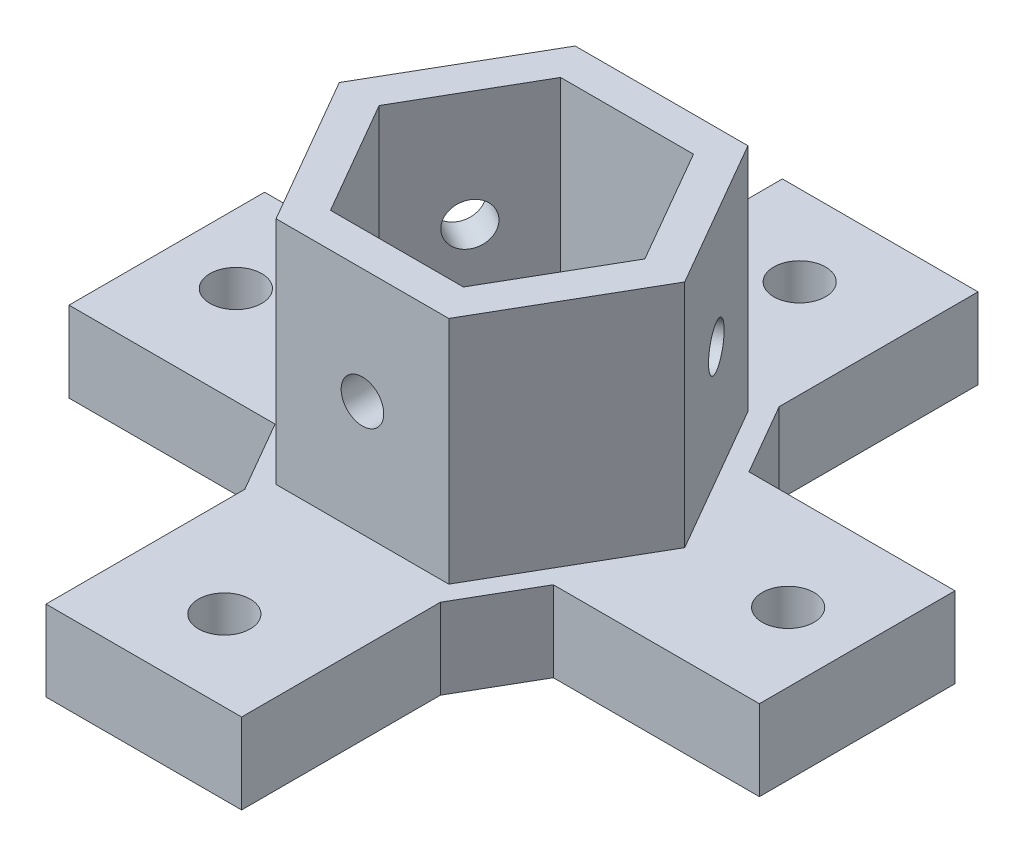
from build123d import *

# Parameters (mm, degrees)
BOSS_EXTRUDE1_DEPTH = 7
BOSS_EXTRUDE2_DEPTH = 20
SKETCH3_R           = 2.25
CUT_EXTRUDE1_DEPTH  = 8
SKETCH4_R           = 2.25
CUT_EXTRUDE2_DEPTH  = 8
SKETCH5_R           = 1.85
CUT_EXTRUDE4_DEPTH  = 3
SKETCH6_R           = 1.85
CUT_EXTRUDE5_DEPTH  = 3
SKETCH7_R           = 1.85
CUT_EXTRUDE6_DEPTH  = 3


with BuildPart() as part:
    # Sketch1 → Boss-Extrude1 (new body)
    with BuildSketch(Plane(origin=(0, 0, 0), x_dir=(1, 0, 0), z_dir=(0, 1, 0))):
        Polygon((12.092522712, -8.5), (30, -8.5), (30, 8.5), (12.092522712, 8.5), (8.5, 14.722431864), (8.5, 32), (-8.5, 32), (-8.5, 14.722431864), (-12.092522712, 8.5), (-30, 8.5), (-30, -8.5), (-12.092522712, -8.5), (-8.5, -14.722431864), (-8.5, -32), (8.5, -32), (8.5, -14.722431864), align=None)
        Polygon((-11.547005384, 0), (-5.773502692, 10), (5.773502692, 10), (11.547005384, 0), (5.773502692, -10), (-5.773502692, -10), align=None, mode=Mode.SUBTRACT)
    extrude(amount=BOSS_EXTRUDE1_DEPTH)

    # Sketch2 → Boss-Extrude2 (add)
    with BuildSketch(Plane(origin=(0, 7, 0), x_dir=(1, 0, 0), z_dir=(0, 1, 0))):
        Polygon((-15.011106999, 0), (-7.505553499, -13), (7.505553499, -13), (15.011106999, 0), (7.505553499, 13), (-7.505553499, 13), align=None)
        Polygon((-11.547005384, 0), (-5.773502692, -10), (5.773502692, -10), (11.547005384, 0), (5.773502692, 10), (-5.773502692, 10), align=None, mode=Mode.SUBTRACT)
    extrude(amount=BOSS_EXTRUDE2_DEPTH)

    # Sketch3 → Cut-Extrude1 (cut, through all)
    with BuildSketch(Plane(origin=(0, 7, 0), x_dir=(1, 0, 0), z_dir=(0, 1, 0))):
        with Locations(Location((0, 25, 0), (0, 0, 270))):  # turned: the seam where the file's is
            Circle(SKETCH3_R)
    cut_extrude1 = extrude(amount=-CUT_EXTRUDE1_DEPTH, mode=Mode.SUBTRACT)

    # Mirror1: Cut-Extrude1 across plane
    add(cut_extrude1.mirror(Plane.XY), mode=Mode.SUBTRACT)

    # Sketch4 → Cut-Extrude2 (cut, through all)
    with BuildSketch(Plane(origin=(0, 7, 0), x_dir=(1, 0, 0), z_dir=(0, 1, 0))):
        with Locations(Location((-24, 0, 0), (0, 0, 270))):  # turned: the seam where the file's is
            Circle(SKETCH4_R)
    cut_extrude2 = extrude(amount=-CUT_EXTRUDE2_DEPTH, mode=Mode.SUBTRACT)

    # Mirror2: Cut-Extrude2 across plane
    add(cut_extrude2.mirror(Plane(origin=(0, 0, 0), x_dir=(0, 0, 1), z_dir=(1, 0, 0))), mode=Mode.SUBTRACT)

    # Sketch5 → Cut-Extrude4 (cut)
    with BuildSketch(Plane.XY.offset(13)):
        with Locations((0, 17)):
            Circle(SKETCH5_R)
    extrude(amount=-CUT_EXTRUDE4_DEPTH, mode=Mode.SUBTRACT)

    # Sketch6 → Cut-Extrude5 (cut)
    with BuildSketch(Plane(origin=(11.258330249, 0, -6.5), x_dir=(-0.5, 0, -0.866025404), z_dir=(0.866025404, 0, -0.5))):
        with Locations((0, 17)):
            Circle(SKETCH6_R)
    extrude(amount=-CUT_EXTRUDE5_DEPTH, mode=Mode.SUBTRACT)

    # Sketch7 → Cut-Extrude6 (cut)
    with BuildSketch(Plane(origin=(-11.258330249, 0, -6.5), x_dir=(-0.5, 0, 0.866025404), z_dir=(-0.866025404, 0, -0.5))):
        with Locations((0, 17)):
            Circle(SKETCH7_R)
    extrude(amount=-CUT_EXTRUDE6_DEPTH, mode=Mode.SUBTRACT)


solid = part.part
